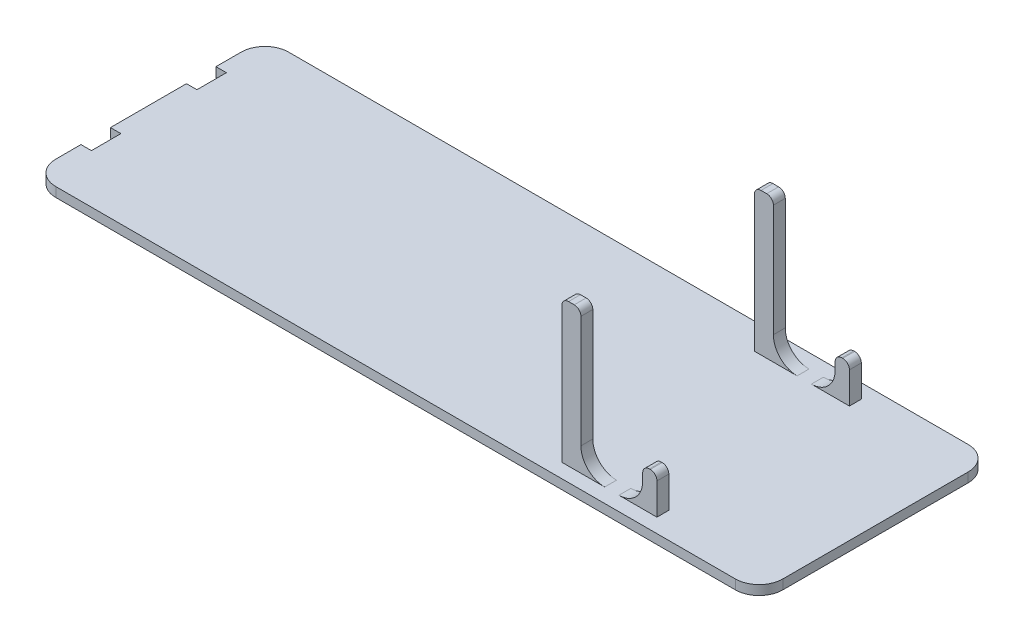
from build123d import *

# Parameters (mm, degrees)
EXTRUDE_3_DEPTH     = 2
CUT_EXTRUDE_START   = -3
SKETCH_4_W          = 2.2
SKETCH_4_H          = 6.2
CUT_EXTRUDE_2_DEPTH = 4
EXTRUDE_4_DEPTH     = 2.5
FILLET_1_R          = 5


with BuildPart() as part:
    # Эскиз1 → Бобышка-Вытянуть3 (new body)
    with BuildSketch(Plane(origin=(0, 0, 0), x_dir=(1, 0, 0), z_dir=(0, 1, 0))):
        with BuildLine():
            Line((71.5, 24.5), (-71.5, 24.5))
            ThreePointArc((-71.5, 24.5), (-75.035533906, 23.035533906), (-76.5, 19.5))
            Line((-76.5, 19.5), (-76.5, -19.5))
            ThreePointArc((-76.5, -19.5), (-75.035533906, -23.035533906), (-71.5, -24.5))
            Line((-71.5, -24.5), (71.5, -24.5))
            ThreePointArc((71.5, -24.5), (75.035533906, -23.035533906), (76.5, -19.5))
            Line((76.5, -19.5), (76.5, 19.5))
            ThreePointArc((76.5, 19.5), (75.035533906, 23.035533906), (71.5, 24.5))
        make_face()
    extrude(amount=-EXTRUDE_3_DEPTH)

    # Эскиз4 → Вырез-Вытянуть2 (cut)
    with BuildSketch(Plane(origin=(0, 0, 0), x_dir=(1, 0, 0), z_dir=(0, 1, 0)).offset(CUT_EXTRUDE_START)):
        with Locations((-75.4, -11.1)):
            Rectangle(SKETCH_4_W, SKETCH_4_H)
    cut_extrude_2 = extrude(amount=CUT_EXTRUDE_2_DEPTH, mode=Mode.SUBTRACT)

    # Зеркальное отражение3: Вырез-Вытянуть2 across plane
    add(cut_extrude_2.mirror(Plane.XY), mode=Mode.SUBTRACT)

    # Эскиз6 → Бобышка-Вытянуть4 (add)
    with BuildSketch(Plane(origin=(0, 0, -21.5), x_dir=(-1, 0, 0), z_dir=(0, 0, -1))):
        with BuildLine():
            ThreePointArc((-36, 28.6), (-35.589949494, 29.589949494), (-34.6, 30))
            Line((-34.6, 30), (-33.4, 30))
            ThreePointArc((-33.4, 30), (-32.410050506, 29.589949494), (-32, 28.6))
            Line((-32, 28.6), (-32, 0))
            Line((-32, 0), (-36, 0))
            Line((-36, 0), (-36, 28.6))
        make_face()
        with BuildLine():
            ThreePointArc((-50.4, 8), (-49.410050506, 7.589949494), (-49, 6.6))
            Line((-49, 6.6), (-49, 0))
            Line((-49, 0), (-52, 0))
            Line((-52, 0), (-52, 6.6))
            ThreePointArc((-52, 6.6), (-51.589949494, 7.589949494), (-50.6, 8))
            Line((-50.6, 8), (-50.4, 8))
        make_face()
    extrude_4 = extrude(amount=-EXTRUDE_4_DEPTH)

    # Зеркальное отражение4: Бобышка-Вытянуть4 across plane
    add(extrude_4.mirror(Plane.XY))

    # Скругление1
    fillet_1_edges = [part.edges().sort_by_distance(p)[0] for p in [
        (36, 0, 20.25),
        (49, 0, 20.25),
        (36, 0, -20.25),
        (49, 0, -20.25),
    ]]
    fillet(fillet_1_edges, radius=FILLET_1_R)


solid = part.part
